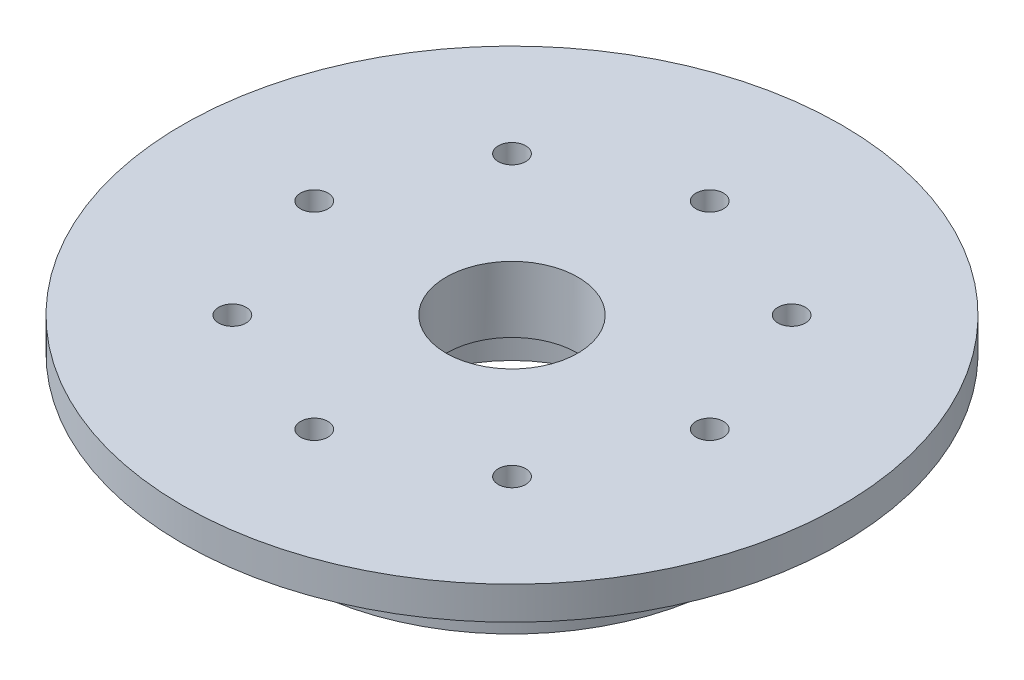
from build123d import *

# Parameters (mm, degrees)
SKETCH1_R             = 30
BOSS_EXTRUDE1_DEPTH   = 3
SKETCH2_R             = 23
BOSS_EXTRUDE2_DEPTH   = 1
SKETCH3_R             = 20
BOSS_EXTRUDE3_DEPTH   = 7
SKETCH12_R            = 10.5
CUT_EXTRUDE1_DEPTH    = 5
SKETCH16_R            = 6
CUT_EXTRUDE2_DEPTH    = 12
M3_TAPPED_HOLE1_D     = 2.5
M3_TAPPED_HOLE1_DEPTH = 29.248924226
M3_TAPPED_HOLE1_TIP   = 0.751075774


with BuildPart() as part:
    # Sketch1 → Boss-Extrude1 (new body)
    with BuildSketch(Plane(origin=(0, 0, 0), x_dir=(1, 0, 0), z_dir=(0, 1, 0))):
        Circle(SKETCH1_R)
    extrude(amount=-BOSS_EXTRUDE1_DEPTH)

    # Sketch2 → Boss-Extrude2 (add)
    with BuildSketch(Plane.XZ.offset(3)):
        Circle(SKETCH2_R)
    extrude(amount=BOSS_EXTRUDE2_DEPTH)

    # Sketch3 → Boss-Extrude3 (add)
    with BuildSketch(Plane.XZ.offset(4)):
        Circle(SKETCH3_R)
    extrude(amount=BOSS_EXTRUDE3_DEPTH)

    # Sketch12 → Cut-Extrude1 (cut)
    with BuildSketch(Plane.XZ.offset(11)):
        Circle(SKETCH12_R)
    extrude(amount=-CUT_EXTRUDE1_DEPTH, mode=Mode.SUBTRACT)

    # Sketch16 → Cut-Extrude2 (cut, through all)
    with BuildSketch(Plane(origin=(0, 0, 0), x_dir=(1, 0, 0), z_dir=(0, 1, 0))):
        Circle(SKETCH16_R)
    extrude(amount=-CUT_EXTRUDE2_DEPTH, mode=Mode.SUBTRACT)

    # M3 Tapped Hole1
    with Locations(Plane(origin=(0, 0, 0), x_dir=(1, 0, 0), z_dir=(0, 1, 0))):
        with Locations((-12.727922061, 12.727922061), (0, 18), (12.727922061, 12.727922061), (18, 0), (12.727922061, -12.727922061), (0, -18), (-12.727922061, -12.727922061), (-18, 0)):
            Hole(M3_TAPPED_HOLE1_D / 2, depth=M3_TAPPED_HOLE1_DEPTH)
            with Locations((0, 0, -(M3_TAPPED_HOLE1_DEPTH + M3_TAPPED_HOLE1_TIP / 2))):  # 118° drill point
                Cone(0, M3_TAPPED_HOLE1_D / 2, M3_TAPPED_HOLE1_TIP, mode=Mode.SUBTRACT)


solid = part.part
